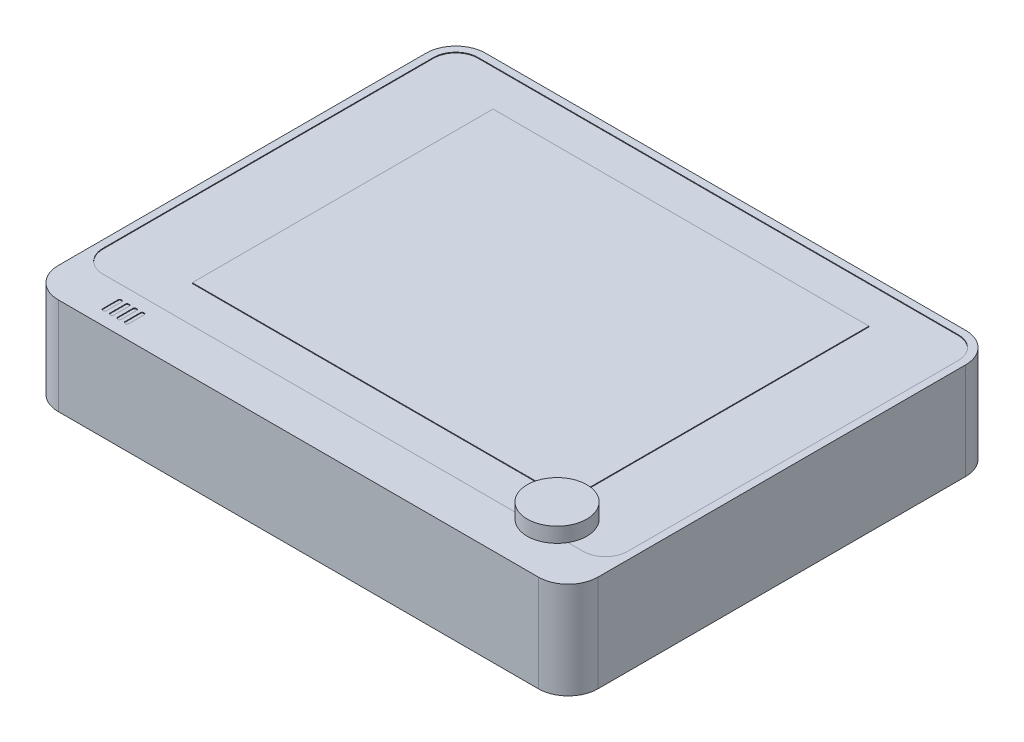
from build123d import *

# Parameters (mm, degrees)
BOSS_EXTRUDE1_DEPTH      = 13
CUT_EXTRUDE1_DEPTH       = 0.1
SKETCH3_W                = 50.5
SKETCH3_H                = 40.4
BOSS_EXTRUDE2_DEPTH      = 0.1
SKETCH4_R                = 2
BOSS_EXTRUDE3_DEPTH      = 1
BOSS_EXTRUDE3_DEPTH_BACK = 1
SKETCH5_R                = 4
BOSS_EXTRUDE4_DEPTH      = 2
SKETCH6_R                = 1
CUT_EXTRUDE3_DEPTH       = 2


with BuildPart() as part:
    # Sketch1 → Boss-Extrude1 (new body)
    with BuildSketch(Plane(origin=(0, 0, 0), x_dir=(1, 0, 0), z_dir=(0, 1, 0))):
        with BuildLine():
            Line((32.25, 28.7), (-32.25, 28.7))
            ThreePointArc((-32.25, 28.7), (-35.078427125, 27.528427125), (-36.25, 24.7))
            Line((-36.25, 24.7), (-36.25, -24.7))
            ThreePointArc((-36.25, -24.7), (-35.078427125, -27.528427125), (-32.25, -28.7))
            Line((-32.25, -28.7), (32.25, -28.7))
            ThreePointArc((32.25, -28.7), (35.078427125, -27.528427125), (36.25, -24.7))
            Line((36.25, -24.7), (36.25, 24.7))
            ThreePointArc((36.25, 24.7), (35.078427125, 27.528427125), (32.25, 28.7))
        make_face()
    extrude(amount=BOSS_EXTRUDE1_DEPTH)

    # Sketch2 → Cut-Extrude1 (cut)
    with BuildSketch(Plane(origin=(0, 13, 0), x_dir=(1, 0, 0), z_dir=(0, 1, 0))):
        with BuildLine():
            Line((-27.25, -26.75), (-27.25, -24.65))
            ThreePointArc((-27.25, -24.65), (-27.191421356, -24.508578644), (-27.05, -24.45))
            Line((-27.05, -24.45), (-26.95, -24.45))
            ThreePointArc((-26.95, -24.45), (-26.808578644, -24.508578644), (-26.75, -24.65))
            Line((-26.75, -24.65), (-26.75, -26.75))
            ThreePointArc((-26.75, -26.75), (-26.808578644, -26.891421356), (-26.95, -26.95))
            Line((-26.95, -26.95), (-27.05, -26.95))
            ThreePointArc((-27.05, -26.95), (-27.191421356, -26.891421356), (-27.25, -26.75))
        make_face()
        with BuildLine():
            Line((-32.25, -22.7), (32.25, -22.7))
            ThreePointArc((32.25, -22.7), (34.371320344, -21.821320344), (35.25, -19.7))
            Line((35.25, -19.7), (35.25, 24.7))
            ThreePointArc((35.25, 24.7), (34.371320344, 26.821320344), (32.25, 27.7))
            Line((32.25, 27.7), (-32.25, 27.7))
            ThreePointArc((-32.25, 27.7), (-34.371320344, 26.821320344), (-35.25, 24.7))
            Line((-35.25, 24.7), (-35.25, -19.7))
            ThreePointArc((-35.25, -19.7), (-34.371320344, -21.821320344), (-32.25, -22.7))
        make_face()
        with BuildLine():
            Line((-28.25, -26.75), (-28.25, -24.65))
            ThreePointArc((-28.25, -24.65), (-28.191421356, -24.508578644), (-28.05, -24.45))
            Line((-28.05, -24.45), (-27.95, -24.45))
            ThreePointArc((-27.95, -24.45), (-27.808578644, -24.508578644), (-27.75, -24.65))
            Line((-27.75, -24.65), (-27.75, -26.75))
            ThreePointArc((-27.75, -26.75), (-27.808578644, -26.891421356), (-27.95, -26.95))
            Line((-27.95, -26.95), (-28.05, -26.95))
            ThreePointArc((-28.05, -26.95), (-28.191421356, -26.891421356), (-28.25, -26.75))
        make_face()
        with BuildLine():
            Line((-26.25, -26.75), (-26.25, -24.65))
            ThreePointArc((-26.25, -24.65), (-26.191421356, -24.508578644), (-26.05, -24.45))
            Line((-26.05, -24.45), (-25.95, -24.45))
            ThreePointArc((-25.95, -24.45), (-25.808578644, -24.508578644), (-25.75, -24.65))
            Line((-25.75, -24.65), (-25.75, -26.75))
            ThreePointArc((-25.75, -26.75), (-25.808578644, -26.891421356), (-25.95, -26.95))
            Line((-25.95, -26.95), (-26.05, -26.95))
            ThreePointArc((-26.05, -26.95), (-26.191421356, -26.891421356), (-26.25, -26.75))
        make_face()
        with BuildLine():
            Line((-25.25, -26.75), (-25.25, -24.65))
            ThreePointArc((-25.25, -24.65), (-25.191421356, -24.508578644), (-25.05, -24.45))
            Line((-25.05, -24.45), (-24.95, -24.45))
            ThreePointArc((-24.95, -24.45), (-24.808578644, -24.508578644), (-24.75, -24.65))
            Line((-24.75, -24.65), (-24.75, -26.75))
            ThreePointArc((-24.75, -26.75), (-24.808578644, -26.891421356), (-24.95, -26.95))
            Line((-24.95, -26.95), (-25.05, -26.95))
            ThreePointArc((-25.05, -26.95), (-25.191421356, -26.891421356), (-25.25, -26.75))
        make_face()
    extrude(amount=-CUT_EXTRUDE1_DEPTH, mode=Mode.SUBTRACT)

    # Sketch3 → Boss-Extrude2 (add)
    with BuildSketch(Plane(origin=(0, 12.9, 0), x_dir=(1, 0, 0), z_dir=(0, 1, 0))):
        with Locations((0, 2.5)):
            Rectangle(SKETCH3_W, SKETCH3_H)
    extrude(amount=BOSS_EXTRUDE2_DEPTH)

    # Sketch4 → Boss-Extrude3 (add, two sides)
    with BuildSketch(Plane(origin=(0, 13, 0), x_dir=(1, 0, 0), z_dir=(0, 1, 0))) as boss_extrude3_sk:
        with Locations(Location((27.75, -21.7, 0), (0, 0, 270))):  # turned: the seam where the file's is
            Circle(SKETCH4_R)
    extrude(amount=BOSS_EXTRUDE3_DEPTH)
    extrude(boss_extrude3_sk.sketch, amount=-BOSS_EXTRUDE3_DEPTH_BACK)

    # Sketch5 → Boss-Extrude4 (add)
    with BuildSketch(Plane(origin=(0, 14, 0), x_dir=(1, 0, 0), z_dir=(0, 1, 0))):
        with Locations(Location((27.75, -21.7, 0), (0, 0, 270))):  # turned: the seam where the file's is
            Circle(SKETCH5_R)
    extrude(amount=BOSS_EXTRUDE4_DEPTH)

    # Sketch6 → Cut-Extrude3 (cut)
    with BuildSketch(Plane.XZ):
        with Locations(Location((30.75, 0, 0), (0, 0, 270))):  # turned: the seam where the file's is
            Circle(SKETCH6_R)
        with Locations(Location((-30.75, 0, 0), (0, 0, 270))):  # turned: the seam where the file's is
            Circle(SKETCH6_R)
    extrude(amount=-CUT_EXTRUDE3_DEPTH, mode=Mode.SUBTRACT)


solid = part.part
